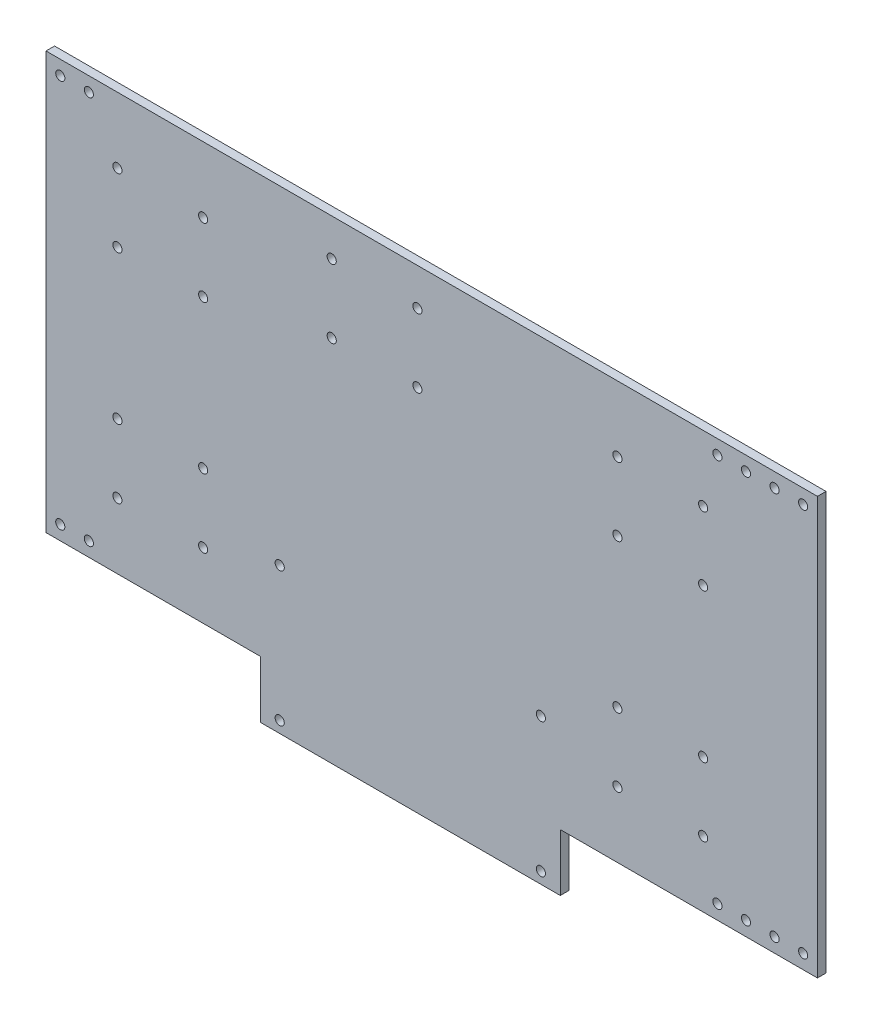
from build123d import *

# Parameters (mm, degrees)
SKETCH_1_R      = 1.6
EXTRUDE_1_DEPTH = 3


with BuildPart() as part:
    # 草图1 → 凸台-拉伸1 (new body)
    with BuildSketch(Plane.XY):
        Polygon((165.87891634, -46.129428967), (185.87891634, -46.129428967), (185.87891634, 99.870571033), (165.87891634, 99.870571033), (95.87891634, 99.870571033), (-9.12108366, 99.870571033), (-79.12108366, 99.870571033), (-84.12108366, 99.870571033), (-84.12108366, -46.129428967), (-79.12108366, -46.129428967), (-9.12108366, -46.129428967), (-9.12108366, -66.129428967), (95.87891634, -66.129428967), (95.87891634, -46.129428967), align=None)
        with Locations((-59.12108366, 0.870571033)):
            Circle(SKETCH_1_R, mode=Mode.SUBTRACT)
        with Locations((-29.12108366, 0.870571033)):
            Circle(SKETCH_1_R, mode=Mode.SUBTRACT)
        with Locations((-59.12108366, -23.129428967)):
            Circle(SKETCH_1_R, mode=Mode.SUBTRACT)
        with Locations((-29.12108366, -23.129428967)):
            Circle(SKETCH_1_R, mode=Mode.SUBTRACT)
        with Locations((115.87891634, 0.870571033)):
            Circle(SKETCH_1_R, mode=Mode.SUBTRACT)
        with Locations((145.87891634, 0.870571033)):
            Circle(SKETCH_1_R, mode=Mode.SUBTRACT)
        with Locations((115.87891634, -23.129428967)):
            Circle(SKETCH_1_R, mode=Mode.SUBTRACT)
        with Locations((145.87891634, -23.129428967)):
            Circle(SKETCH_1_R, mode=Mode.SUBTRACT)
        with Locations((-2.32108366, -62.129428967)):
            Circle(SKETCH_1_R, mode=Mode.SUBTRACT)
        with Locations((-2.32108366, -15.129428967)):
            Circle(SKETCH_1_R, mode=Mode.SUBTRACT)
        with Locations((89.07891634, -15.129428967)):
            Circle(SKETCH_1_R, mode=Mode.SUBTRACT)
        with Locations((89.07891634, -62.129428967)):
            Circle(SKETCH_1_R, mode=Mode.SUBTRACT)
        with Locations((145.87891634, 76.870571033)):
            Circle(SKETCH_1_R, mode=Mode.SUBTRACT)
        with Locations((115.87891634, 76.870571033)):
            Circle(SKETCH_1_R, mode=Mode.SUBTRACT)
        with Locations((145.87891634, 52.870571033)):
            Circle(SKETCH_1_R, mode=Mode.SUBTRACT)
        with Locations((115.87891634, 52.870571033)):
            Circle(SKETCH_1_R, mode=Mode.SUBTRACT)
        with Locations((-29.12108366, 76.870571033)):
            Circle(SKETCH_1_R, mode=Mode.SUBTRACT)
        with Locations((-59.12108366, 76.870571033)):
            Circle(SKETCH_1_R, mode=Mode.SUBTRACT)
        with Locations((-29.12108366, 52.870571033)):
            Circle(SKETCH_1_R, mode=Mode.SUBTRACT)
        with Locations((-59.12108366, 52.870571033)):
            Circle(SKETCH_1_R, mode=Mode.SUBTRACT)
        with Locations((15.87891634, 86.870571033)):
            Circle(SKETCH_1_R, mode=Mode.SUBTRACT)
        with Locations((45.87891634, 86.870571033)):
            Circle(SKETCH_1_R, mode=Mode.SUBTRACT)
        with Locations((15.87891634, 62.870571033)):
            Circle(SKETCH_1_R, mode=Mode.SUBTRACT)
        with Locations((45.87891634, 62.870571033)):
            Circle(SKETCH_1_R, mode=Mode.SUBTRACT)
        with Locations((-79.12108366, -41.129428967)):
            Circle(SKETCH_1_R, mode=Mode.SUBTRACT)
        with Locations((-69.12108366, -41.129428967)):
            Circle(SKETCH_1_R, mode=Mode.SUBTRACT)
        with Locations((-79.12108366, 94.870571033)):
            Circle(SKETCH_1_R, mode=Mode.SUBTRACT)
        with Locations((-69.12108366, 94.870571033)):
            Circle(SKETCH_1_R, mode=Mode.SUBTRACT)
        with Locations((180.87891634, -41.129428967)):
            Circle(SKETCH_1_R, mode=Mode.SUBTRACT)
        with Locations((170.87891634, -41.129428967)):
            Circle(SKETCH_1_R, mode=Mode.SUBTRACT)
        with Locations((160.87891634, -41.129428967)):
            Circle(SKETCH_1_R, mode=Mode.SUBTRACT)
        with Locations((150.87891634, -41.129428967)):
            Circle(SKETCH_1_R, mode=Mode.SUBTRACT)
        with Locations((180.87891634, 94.870571033)):
            Circle(SKETCH_1_R, mode=Mode.SUBTRACT)
        with Locations((170.87891634, 94.870571033)):
            Circle(SKETCH_1_R, mode=Mode.SUBTRACT)
        with Locations((160.87891634, 94.870571033)):
            Circle(SKETCH_1_R, mode=Mode.SUBTRACT)
        with Locations((150.87891634, 94.870571033)):
            Circle(SKETCH_1_R, mode=Mode.SUBTRACT)
    extrude(amount=EXTRUDE_1_DEPTH)


solid = part.part
